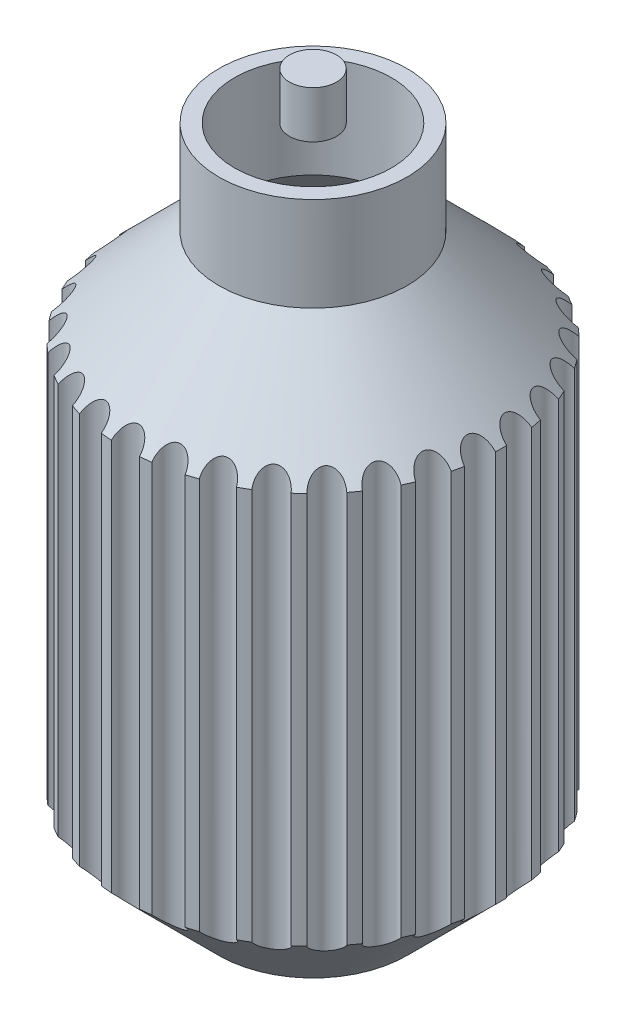
from build123d import *

# Parameters (mm, degrees)
SHELL1_T            = -5
SKETCH6_R           = 4.5
CUT_EXTRUDE1_DEPTH  = 232.138486627
CIRPATTERN1_COUNT   = 30
SKETCH7_R           = 7.5
BOSS_EXTRUDE1_DEPTH = 15


with BuildPart() as part:
    # Sketch1 → Revolve1 (revolve)
    with BuildSketch(Plane.XY, mode=Mode.PRIVATE) as revolve1_sk:
        Polygon((-30, 0), (-30, -30), (-60, -60), (-60, -185), (-30, -215), (0, -215), (0, 0), align=None)
    revolve(revolve1_sk.sketch.rotate(Axis((0, 0, 0), (0, -1, 0)), 270), axis=Axis((0, 0, 0), (0, -1, 0)))

    # Shell1
    shell1_openings = [part.faces().sort_by_distance(p)[0] for p in [
        (0, 0, 0),
    ]]
    offset(amount=SHELL1_T, openings=shell1_openings, kind=Kind.INTERSECTION)

    # Sketch6 → Cut-Extrude1 (cut, through all)
    with BuildSketch(Plane(origin=(0, 0, 0), x_dir=(1, 0, 0), z_dir=(0, 1, 0))):
        with Locations((0, 60)):
            Circle(SKETCH6_R)
    cut_extrude1 = extrude(amount=-CUT_EXTRUDE1_DEPTH, mode=Mode.SUBTRACT)

    # CirPattern1: Cut-Extrude1 ×30 about axis
    cirpattern1_axis = Axis((0, 0, 0), (0, 1, 0))
    for i in range(1, CIRPATTERN1_COUNT):
        add(cut_extrude1.rotate(cirpattern1_axis, i * 360 / CIRPATTERN1_COUNT), mode=Mode.SUBTRACT)


with BuildPart() as body_2:
    # Sketch7 → Boss-Extrude1 (new body)
    with BuildSketch(Plane(origin=(0, 0, 0), x_dir=(1, 0, 0), z_dir=(0, 1, 0))):
        with Locations(Location((0, 0, 0), (0, 0, 270))):
            Circle(SKETCH7_R)
    extrude(amount=BOSS_EXTRUDE1_DEPTH)


solid = Compound([part.part, body_2.part])
